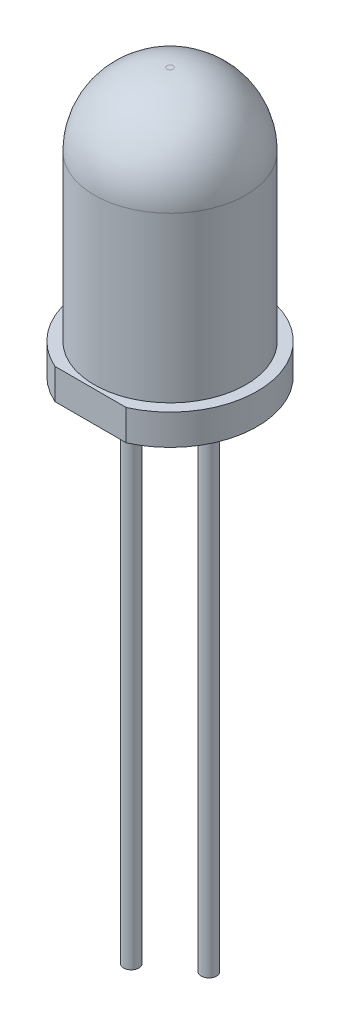
from build123d import *

# Parameters (mm, degrees)
CUT_EXTRUDE1_DEPTH  = 1
SKETCH3_R           = 0.25
BOSS_EXTRUDE1_DEPTH = 16
SKETCH4_R           = 0.25
BOSS_EXTRUDE2_DEPTH = 1.5


with BuildPart() as part:
    # Sketch1 → Revolve1 (revolve)
    with BuildSketch(Plane.XY):
        with BuildLine():
            Line((0, 0), (0, 8.75))
            Line((0, 8.75), (0.1, 8.75))
            ThreePointArc((0.1, 8.75), (1.782914139, 8.052914139), (2.48, 6.37))
            Line((2.48, 6.37), (2.48, 1))
            Line((2.48, 1), (2.85, 1))
            Line((2.85, 1), (2.85, 0))
            Line((2.85, 0), (0, 0))
        make_face()
    revolve(axis=Axis((0, 0, 0), (0, 1, 0)))

    # Sketch2 → Cut-Extrude1 (cut)
    with BuildSketch(Plane.XZ):
        with BuildLine():
            Line((-1.167261753, 2.6), (1.167261753, 2.6))
            ThreePointArc((1.167261753, 2.6), (0, 2.85), (-1.167261753, 2.6))
        make_face()
    extrude(amount=-CUT_EXTRUDE1_DEPTH, mode=Mode.SUBTRACT)

    # Sketch3 → Boss-Extrude1 (add)
    with BuildSketch(Plane.XZ):
        with Locations((0, -1.27)):
            Circle(SKETCH3_R)
        with Locations((0, 1.27)):
            Circle(SKETCH3_R)
    extrude(amount=BOSS_EXTRUDE1_DEPTH)

    # Sketch4 → Boss-Extrude2 (add)
    with BuildSketch(Plane.XZ.offset(16)):
        with Locations((0, -1.27)):
            Circle(SKETCH4_R)
    extrude(amount=BOSS_EXTRUDE2_DEPTH)


solid = part.part
